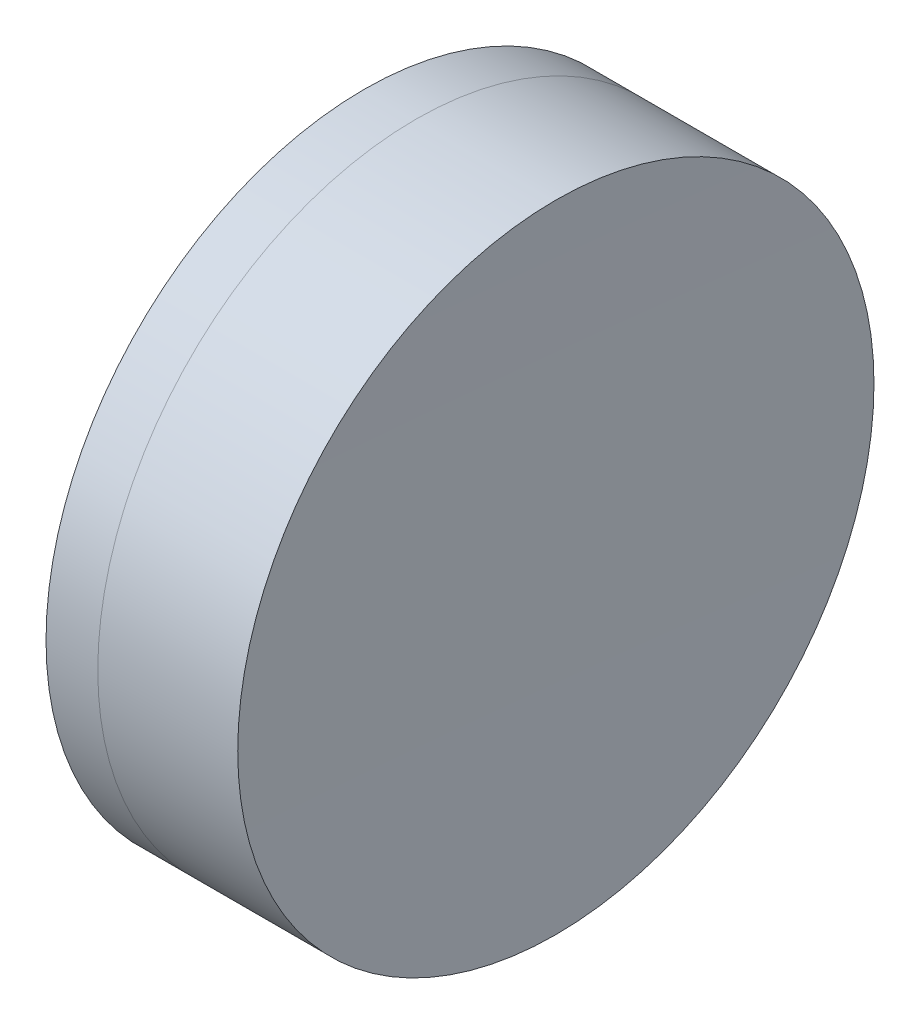
from build123d import *


with BuildPart() as part:
    # 草图1 one side → 旋转1 (revolve)
    with BuildSketch(Plane(origin=(0, 0, 0), x_dir=(1, 0, 0), z_dir=(0, 1, 0)), mode=Mode.PRIVATE) as revolve_1_sk:
        with BuildLine():
            ThreePointArc((34.700277422, 12.7), (31.84402908, 6.633376716), (30.864036214, 0))
            Line((30.864036214, 0), (40.464036214, 0))
            ThreePointArc((40.464036214, 0), (39.520889377, 6.613636093), (36.766641255, 12.7))
            Line((36.766641255, 12.7), (34.700277422, 12.7))
        make_face()
    revolve(revolve_1_sk.sketch.rotate(Axis((-0.816062176, 0, 0), (1, 0, 0)), 180), axis=Axis((-0.816062176, 0, 0), (1, 0, 0)))  # turned: the seam where the file's is


with BuildPart() as body_2:
    # 草图2 one side → 旋转2 (revolve)
    with BuildSketch(Plane(origin=(0, 0, 0), x_dir=(1, 0, 0), z_dir=(0, 1, 0)), mode=Mode.PRIVATE) as revolve_2_sk:
        with BuildLine():
            Line((42.353646231, 12.7), (36.766641255, 12.7))
            ThreePointArc((36.766641255, 12.7), (39.520889377, 6.613636093), (40.464036214, 0))
            Line((40.464036214, 0), (42.264036214, 0))
            ThreePointArc((42.264036214, 0), (42.286438997, 6.350158068), (42.353646231, 12.7))
        make_face()
    revolve(revolve_2_sk.sketch.rotate(Axis((-0.551919993, 0, 0), (1, 0, 0)), 180), axis=Axis((-0.551919993, 0, 0), (1, 0, 0)))  # turned: the seam where the file's is


solid = Compound([part.part, body_2.part])
